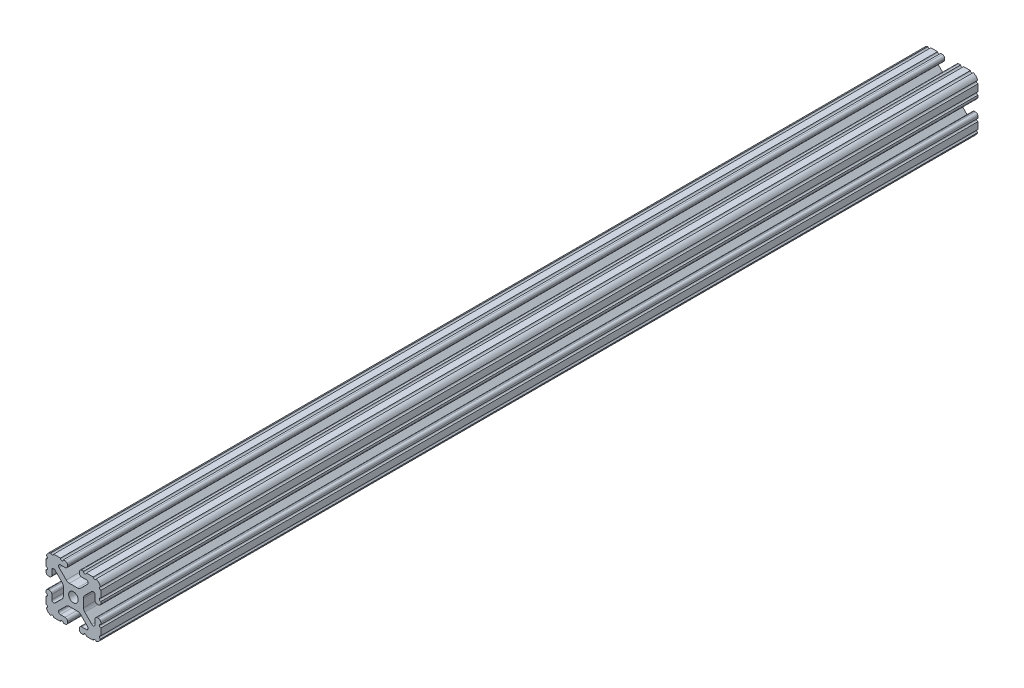
from build123d import *

# Parameters (mm, degrees)
BOSS_EXTRUDE1_DEPTH     = 304.8
SKETCH5_R               = 1.016
CUT_EXTRUDE1_DEPTH      = 305.8
CUT_EXTRUDE1_DEPTH_BACK = 305.8


with BuildPart() as part:
    # Sketch4 → Boss-Extrude1 (new body, symmetric)
    with BuildSketch(Plane.XY):
        with BuildLine():
            Line((5.7912, -19.05), (14.3002, -19.05))
            ThreePointArc((14.3002, -19.05), (17.658815789, -17.658815789), (19.05, -14.3002))
            Line((19.05, -14.3002), (19.05, -5.7912))
            ThreePointArc((19.05, -5.7912), (18.544114832, -4.569885168), (17.3228, -4.064))
            Line((17.3228, -4.064), (16.7132, -4.064))
            ThreePointArc((16.7132, -4.064), (15.491885168, -4.569885168), (14.986, -5.7912))
            Line((14.986, -5.7912), (14.986, -8.996305235))
            ThreePointArc((14.986, -8.996305235), (14.189232738, -10.188751711), (12.782646215, -9.908964256))
            Line((12.782646215, -9.908964256), (7.888897763, -5.015215804))
            ThreePointArc((7.888897763, -5.015215804), (7.219915375, -4.014012907), (6.985, -2.833013566))
            Line((6.985, -2.833013566), (6.985, 0))
            Line((6.985, 0), (3.3274, 0))
            ThreePointArc((3.3274, 0), (2.352827104, -2.352827104), (0, -3.3274))
            Line((0, -3.3274), (0, -6.985))
            Line((0, -6.985), (2.833013566, -6.985))
            ThreePointArc((2.833013566, -6.985), (4.014012907, -7.219915375), (5.015215804, -7.888897763))
            Line((5.015215804, -7.888897763), (9.908964256, -12.782646215))
            ThreePointArc((9.908964256, -12.782646215), (10.188751711, -14.189232738), (8.996305235, -14.986))
            Line((8.996305235, -14.986), (5.7912, -14.986))
            ThreePointArc((5.7912, -14.986), (4.569885168, -15.491885168), (4.064, -16.7132))
            Line((4.064, -16.7132), (4.064, -17.3228))
            ThreePointArc((4.064, -17.3228), (4.569885168, -18.544114832), (5.7912, -19.05))
        make_face()
    extrude(amount=BOSS_EXTRUDE1_DEPTH, both=True)

    # Sketch5 → Cut-Extrude1 (cut, two sides)
    with BuildSketch(Plane.XY) as cut_extrude1_sk:
        with Locations((14.739477062, -19.05)):
            Circle(SKETCH5_R)
        with Locations((7.980305235, -19.05)):
            Circle(SKETCH5_R)
        with Locations((19.05, -14.739477062)):
            Circle(SKETCH5_R)
        with Locations((19.05, -7.980305235)):
            Circle(SKETCH5_R)
    extrude(amount=CUT_EXTRUDE1_DEPTH, mode=Mode.SUBTRACT)
    extrude(cut_extrude1_sk.sketch, amount=-CUT_EXTRUDE1_DEPTH_BACK, mode=Mode.SUBTRACT)

    # Mirror1: part across plane


with BuildPart() as part_1:
    add(part.part)
    add(part.part.mirror(Plane(origin=(0, 0, 0), x_dir=(0, 0, 1), z_dir=(1, 0, 0))))

    # Mirror2: part across plane


with BuildPart() as part_2:
    add(part_1.part)
    add(part_1.part.mirror(Plane.ZX))


solid = part_2.part
